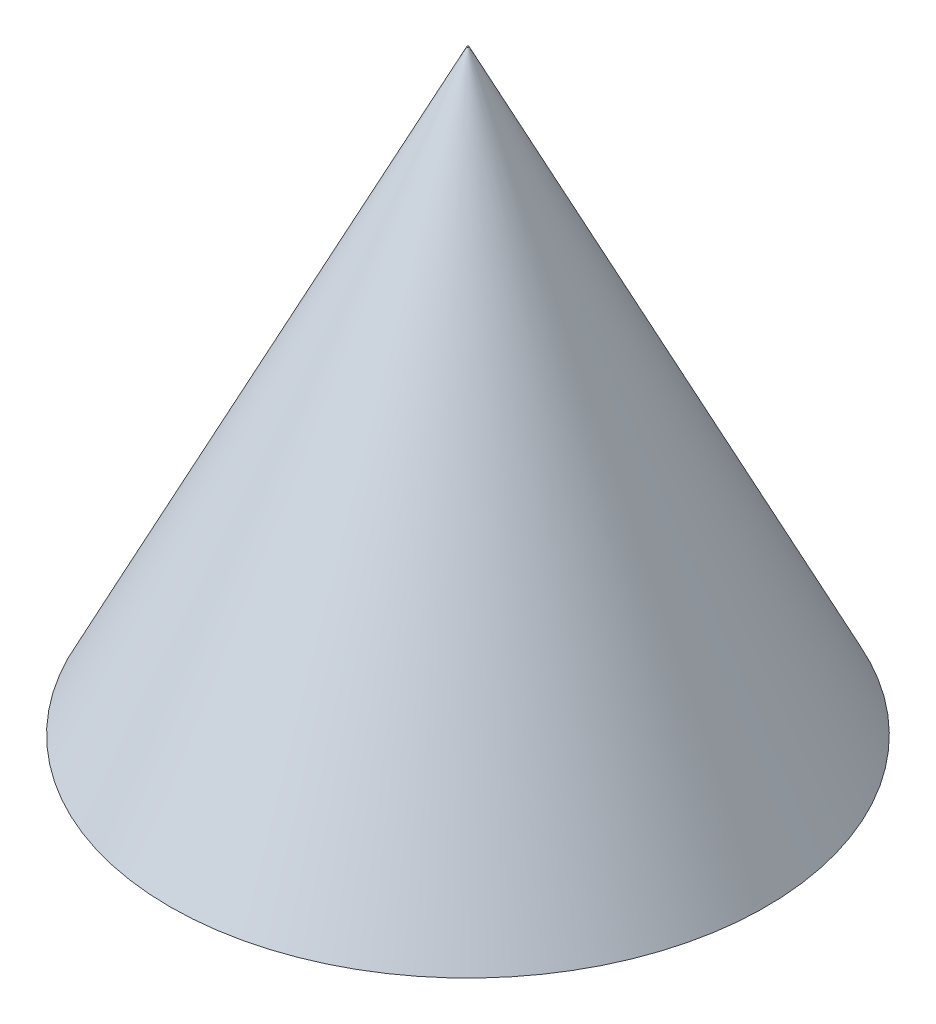
from build123d import *

# Parameters (mm, degrees)
ESQUISSE1_R        = 29
BOSS_EXTRU_1_DEPTH = 58
BOSS_EXTRU_1_TAPER = 26.5


with BuildPart() as part:
    # Esquisse1 → Boss.-Extru.1 (new body)
    with BuildSketch(Plane(origin=(0, 0, 0), x_dir=(1, 0, 0), z_dir=(0, 1, 0))):
        Circle(ESQUISSE1_R)
    extrude(amount=BOSS_EXTRU_1_DEPTH, taper=BOSS_EXTRU_1_TAPER)


solid = part.part
